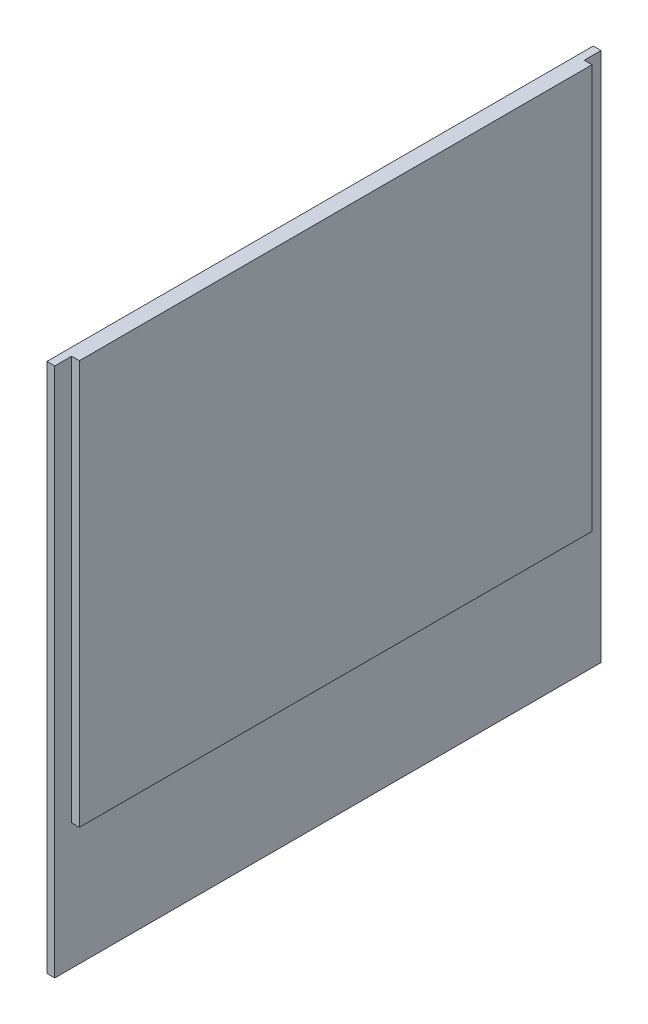
from build123d import *

# Parameters (mm, degrees)
SKETCH1_W           = 111.252
SKETCH1_H           = 107.95
BOSS_EXTRUDE1_DEPTH = 1.5875
SKETCH2_W           = 104.394
SKETCH2_H           = 82.296
BOSS_EXTRUDE2_DEPTH = 1.5875


with BuildPart() as part:
    # Sketch1 → Boss-Extrude1 (new body)
    with BuildSketch(Plane(origin=(0, 0, 0), x_dir=(0, 0, -1), z_dir=(1, 0, 0))):
        with Locations((55.626, 53.975)):
            Rectangle(SKETCH1_W, SKETCH1_H)
    extrude(amount=BOSS_EXTRUDE1_DEPTH)

    # Sketch2 → Boss-Extrude2 (add)
    with BuildSketch(Plane(origin=(1.5875, 0, 0), x_dir=(0, 0, -1), z_dir=(1, 0, 0))):
        with Locations((55.626, 66.802)):
            Rectangle(SKETCH2_W, SKETCH2_H)
    extrude(amount=BOSS_EXTRUDE2_DEPTH)


solid = part.part
